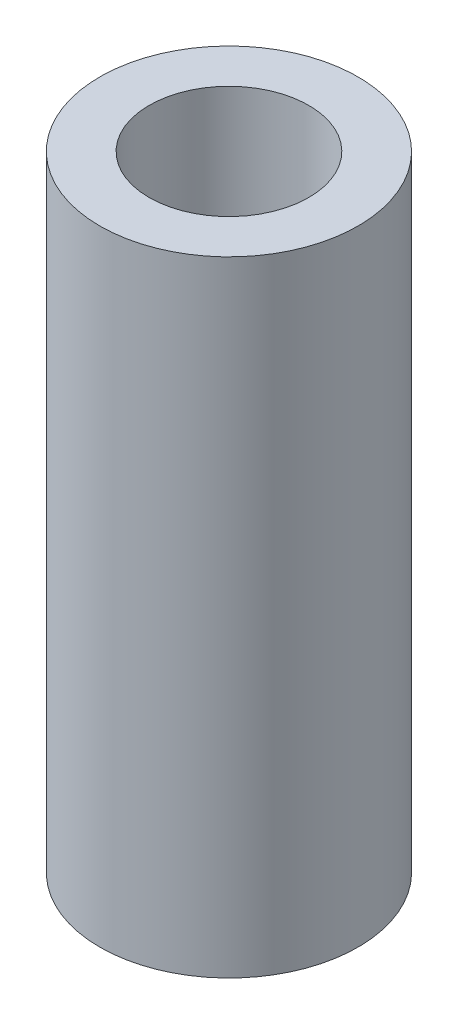
from build123d import *

# Parameters (mm, degrees)
SKETCH1_R           = 3.4925
SKETCH1_R_2         = 2.159
BOSS_EXTRUDE1_DEPTH = 8.4455


with BuildPart() as part:
    # Sketch1 → Boss-Extrude1 (new body, symmetric)
    with BuildSketch(Plane(origin=(0, 0, 0), x_dir=(1, 0, 0), z_dir=(0, 1, 0))):
        Circle(SKETCH1_R)
        Circle(SKETCH1_R_2, mode=Mode.SUBTRACT)
    extrude(amount=BOSS_EXTRUDE1_DEPTH, both=True)


solid = part.part
